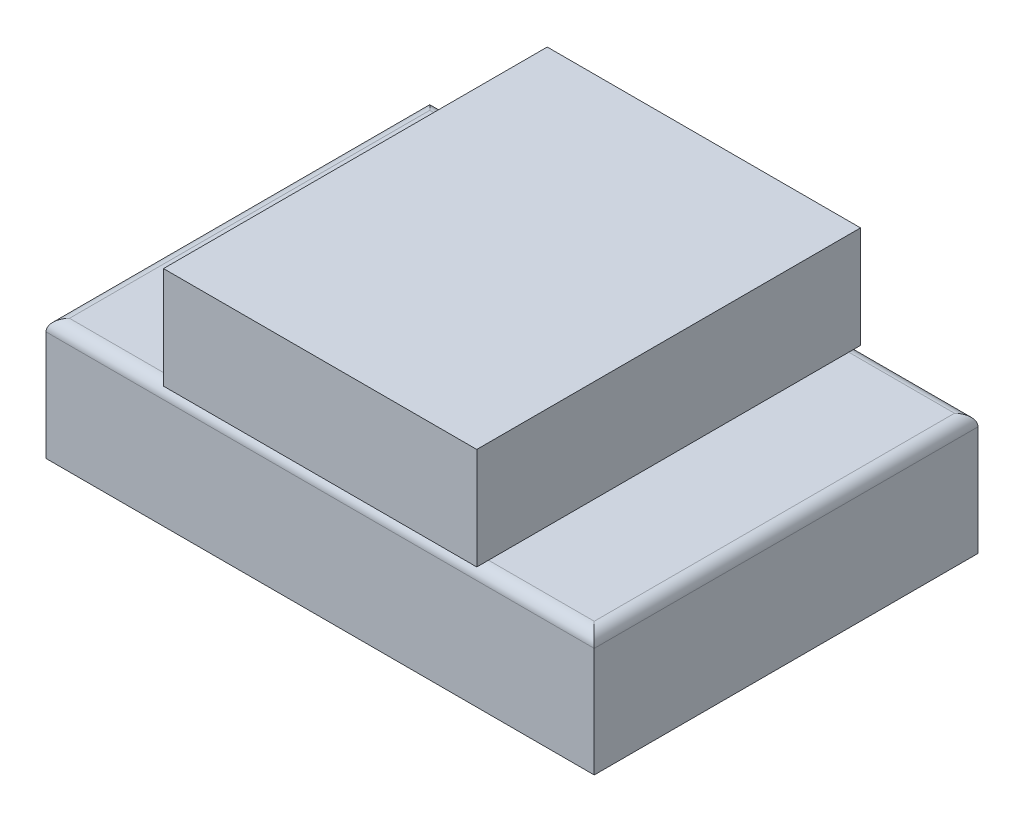
from build123d import *

# Parameters (mm, degrees)
SKETCH2_W           = 40
SKETCH2_H           = 49
BOSS_EXTRUDE1_DEPTH = 13
SKETCH2_3_W         = 70
SKETCH2_3_H         = 49
BOSS_EXTRUDE2_DEPTH = 15.5
FILLET2_R           = 1.5


with BuildPart() as part:
    # Sketch2 → Boss-Extrude1 (new body)
    with BuildSketch(Plane(origin=(0, 0, 0), x_dir=(1, 0, 0), z_dir=(0, 1, 0))):
        Rectangle(SKETCH2_W, SKETCH2_H)
    extrude(amount=BOSS_EXTRUDE1_DEPTH)


with BuildPart() as body_2:
    # Sketch2_3 → Boss-Extrude2 (new body)
    with BuildSketch(Plane(origin=(0, 0, 0), x_dir=(1, 0, 0), z_dir=(0, 1, 0))):
        Rectangle(SKETCH2_3_W, SKETCH2_3_H)
    extrude(amount=-BOSS_EXTRUDE2_DEPTH)

    # Fillet2
    fillet2_edges = [body_2.edges().sort_by_distance(p)[0] for p in [
        (-35, 0, 0),
        (0, 0, 24.5),
        (0, 0, -24.5),
        (35, 0, 0),
    ]]
    fillet(fillet2_edges, radius=FILLET2_R)


solid = Compound([part.part, body_2.part])
